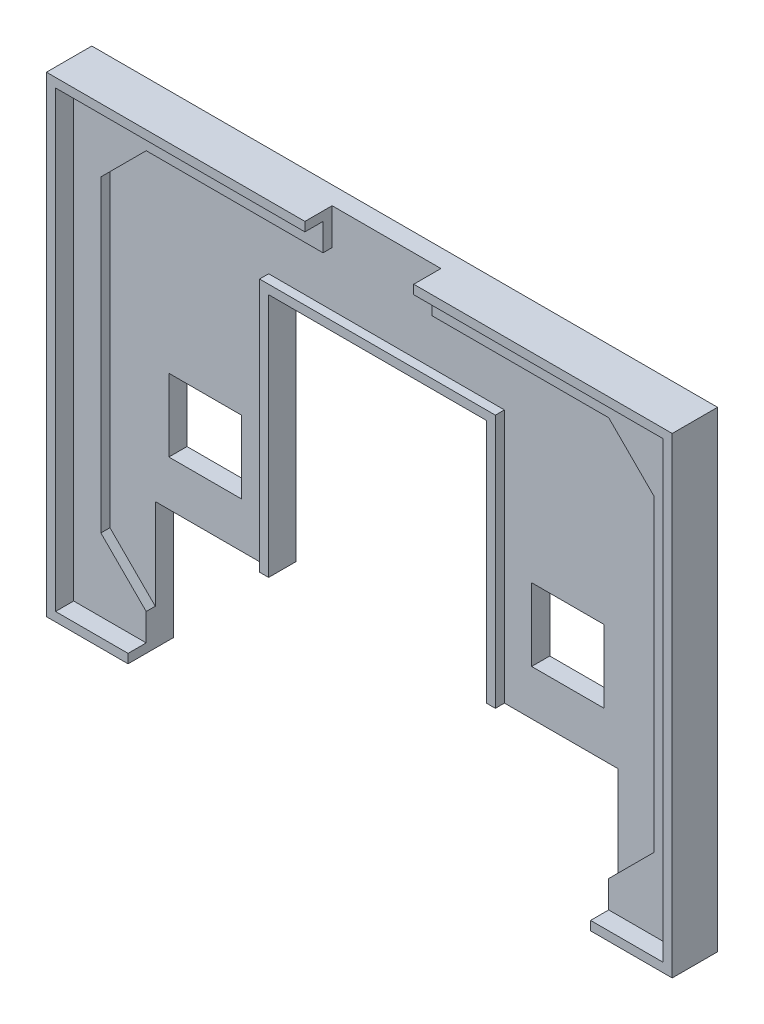
from build123d import *

# Parameters (mm, degrees)
SKICA1_W                    = 67
SKICA1_H                    = 50
P_IDAT_VYSUNUT_M1_DEPTH     = 3
ODEBRAT_VYSUNUT_M1_DEPTH    = 1
SKICA3_W                    = 8
SKICA3_H                    = 8
ODEBRAT_VYSUNUT_M2_DEPTH    = 4
VYSUNOUT_TENKOST_NN_1_DEPTH = 1
VYSUNOUT_TENKOST_NN_2_DEPTH = 5
SKICA6_W                    = 12
SKICA6_H                    = 4
ODEBRAT_VYSUNUT_M3_DEPTH    = 4
ODEBRAT_VYSUNUT_M4_DEPTH    = 1
P_IDAT_START                = -1
SKICA8_W                    = 2
SKICA8_H                    = 2
P_IDAT_VYSUNUT_M2_DEPTH     = 1
ODEBRAT_VYSUNUT_M5_DEPTH    = 1
SKICA10_W                   = 1.6
SKICA10_H                   = 2.4
SKICA10_H_2                 = 1.6
P_IDAT_VYSUNUT_M3_DEPTH     = 1


with BuildPart() as part:
    # Skica1 → Přidat vysunutím1 (new body)
    with BuildSketch(Plane.XY):
        Rectangle(SKICA1_W, SKICA1_H)
    extrude(amount=P_IDAT_VYSUNUT_M1_DEPTH)

    # Skica2 → Odebrat vysunutím1 (cut)
    with BuildSketch(Plane.XY.offset(3)):
        Polygon((-25.5, -22), (-30.5, -17), (-30.5, 17), (-25.5, 22), (25.5, 22), (30.5, 17), (30.5, -17), (25.5, -22), align=None)
    extrude(amount=-ODEBRAT_VYSUNUT_M1_DEPTH, mode=Mode.SUBTRACT)

    # Skica3 → Odebrat vysunutím2 (cut, through all)
    with BuildSketch(Plane(origin=(0, 0, 0), x_dir=(-1, 0, 0), z_dir=(0, 0, -1))):
        with Locations((20, -3)):
            Rectangle(SKICA3_W, SKICA3_H)
        with Locations((-20, -3)):
            Rectangle(SKICA3_W, SKICA3_H)
        Polygon((25.5, -25), (-25.5, -25), (-25.5, -12), (-12, -12), (-12, 15), (12, 15), (12, -12), (25.5, -12), align=None)
    extrude(amount=-ODEBRAT_VYSUNUT_M2_DEPTH, mode=Mode.SUBTRACT)

    # Skica4 → Vysunout tenkostěnný1 (add)
    with BuildSketch(Plane.XY.offset(2)):
        Polygon((-12, -12), (-12, 15), (12, 15), (12, -12), (13, -12), (13, 16), (-13, 16), (-13, -12), align=None)
    extrude(amount=VYSUNOUT_TENKOST_NN_1_DEPTH)

    # Skica5 → Vysunout tenkostěnný2 (add)
    with BuildSketch(Plane(origin=(0, 0, 0), x_dir=(-1, 0, 0), z_dir=(0, 0, -1))):
        Polygon((-25.5, -25), (-33.5, -25), (-33.5, 25), (33.5, 25), (33.5, -25), (25.5, -25), (25.5, -26), (34.5, -26), (34.5, 26), (-34.5, 26), (-34.5, -26), (-25.5, -26), align=None)
    extrude(amount=-VYSUNOUT_TENKOST_NN_2_DEPTH)

    # Skica6 → Odebrat vysunutím3 (cut, through all)
    with BuildSketch(Plane.XY.offset(2)):
        with Locations((0, 24)):
            Rectangle(SKICA6_W, SKICA6_H)
    extrude(amount=ODEBRAT_VYSUNUT_M3_DEPTH, mode=Mode.SUBTRACT)

    # Skica7 → Odebrat vysunutím4 (cut)
    with BuildSketch(Plane(origin=(0, 0, 0), x_dir=(-1, 0, 0), z_dir=(0, 0, -1))):
        Polygon((-28.75, 22), (-26.75, 22), (-26.75, 21), (-25.75, 21), (-25.75, 16), (-20.75, 16), (-20.75, 21), (-19.75, 21), (-19.75, 22), (-17.75, 22), (-17.75, 21), (-16.75, 21), (-16.75, 14), (-15.75, 14), (-15.75, 8), (-16.75, 8), (-16.75, 7), (-17.75, 7), (-17.75, 6), (-18.75, 6), (-18.75, 5), (-27.75, 5), (-27.75, 6), (-28.75, 6), (-28.75, 7), (-29.75, 7), (-29.75, 8), (-30.75, 8), (-30.75, 14), (-29.75, 14), (-29.75, 21), (-28.75, 21), align=None)
        Polygon((18.75, 6), (18.75, 5), (27.75, 5), (27.75, 6), (28.75, 6), (28.75, 7), (29.75, 7), (29.75, 8), (30.75, 8), (30.75, 14), (29.75, 14), (29.75, 21), (28.75, 21), (28.75, 22), (26.75, 22), (26.75, 21), (25.75, 21), (25.75, 16), (20.75, 16), (20.75, 21), (19.75, 21), (19.75, 22), (17.75, 22), (17.75, 21), (16.75, 21), (16.75, 14), (15.75, 14), (15.75, 8), (16.75, 8), (16.75, 7), (17.75, 7), (17.75, 6), align=None)
    extrude(amount=-ODEBRAT_VYSUNUT_M4_DEPTH, mode=Mode.SUBTRACT)

    # Skica8 → Přidat vysunutím2 (add)
    with BuildSketch(Plane(origin=(0, 0, 0), x_dir=(-1, 0, 0), z_dir=(0, 0, -1)).offset(P_IDAT_START)):
        with Locations((-26.75, 11)):
            Rectangle(SKICA8_W, SKICA8_H)
        with Locations((-19.75, 11)):
            Rectangle(SKICA8_W, SKICA8_H)
        Polygon((-23.75, 10), (-22.75, 10), (-22.75, 9), (-21.75, 9), (-21.75, 8), (-24.75, 8), (-24.75, 9), (-23.75, 9), align=None)
        Polygon((24.75, 9), (23.75, 9), (23.75, 10), (22.75, 10), (22.75, 9), (21.75, 9), (21.75, 8), (24.75, 8), align=None)
        with Locations((26.75, 11)):
            Rectangle(SKICA8_W, SKICA8_H)
        with Locations((19.75, 11)):
            Rectangle(SKICA8_W, SKICA8_H)
    extrude(amount=P_IDAT_VYSUNUT_M2_DEPTH)

    # Skica9 → Odebrat vysunutím5 (cut)
    with BuildSketch(Plane(origin=(0, 0, 0), x_dir=(-1, 0, 0), z_dir=(0, 0, -1))):
        Polygon((-11.2, 23.3), (-9.6, 23.3), (-9.6, 19.3), (-8.8, 19.3), (-8.8, 21.7), (-8, 21.7), (-8, 19.3), (-7.2, 19.3), (-7.2, 23.3), (-5.6, 23.3), (-5.6, 18.5), (-6.4, 18.5), (-6.4, 17.7), (-8, 17.7), (-8, 18.5), (-8.8, 18.5), (-8.8, 17.7), (-10.4, 17.7), (-10.4, 18.5), (-11.2, 18.5), align=None)
        Polygon((-4.8, 23.3), (-3.2, 23.3), (-3.2, 20.9), (-1.6, 20.9), (-1.6, 23.3), (0, 23.3), (0, 17.7), (-1.6, 17.7), (-1.6, 20.1), (-3.2, 20.1), (-3.2, 17.7), (-4.8, 17.7), align=None)
        Polygon((1.6, 23.3), (4.8, 23.3), (4.8, 22.5), (5.6, 22.5), (5.6, 18.5), (4.8, 18.5), (4.8, 17.7), (1.6, 17.7), (1.6, 18.5), (0.8, 18.5), (0.8, 22.5), (1.6, 22.5), align=None)
        Polygon((6.4, 23.3), (10.4, 23.3), (10.4, 22.5), (11.2, 22.5), (11.2, 20.9), (10.4, 20.9), (10.4, 20.1), (8, 20.1), (8, 17.7), (6.4, 17.7), align=None)
    extrude(amount=-ODEBRAT_VYSUNUT_M5_DEPTH, mode=Mode.SUBTRACT)

    # Skica10 → Přidat vysunutím3 (add)
    with BuildSketch(Plane(origin=(0, 0, 0), x_dir=(-1, 0, 0), z_dir=(0, 0, -1)).offset(P_IDAT_START)):
        with Locations((3.2, 20.5)):
            Rectangle(SKICA10_W, SKICA10_H)
        with Locations((8.8, 21.7)):
            Rectangle(SKICA10_W, SKICA10_H_2)
    extrude(amount=P_IDAT_VYSUNUT_M3_DEPTH)


solid = part.part
